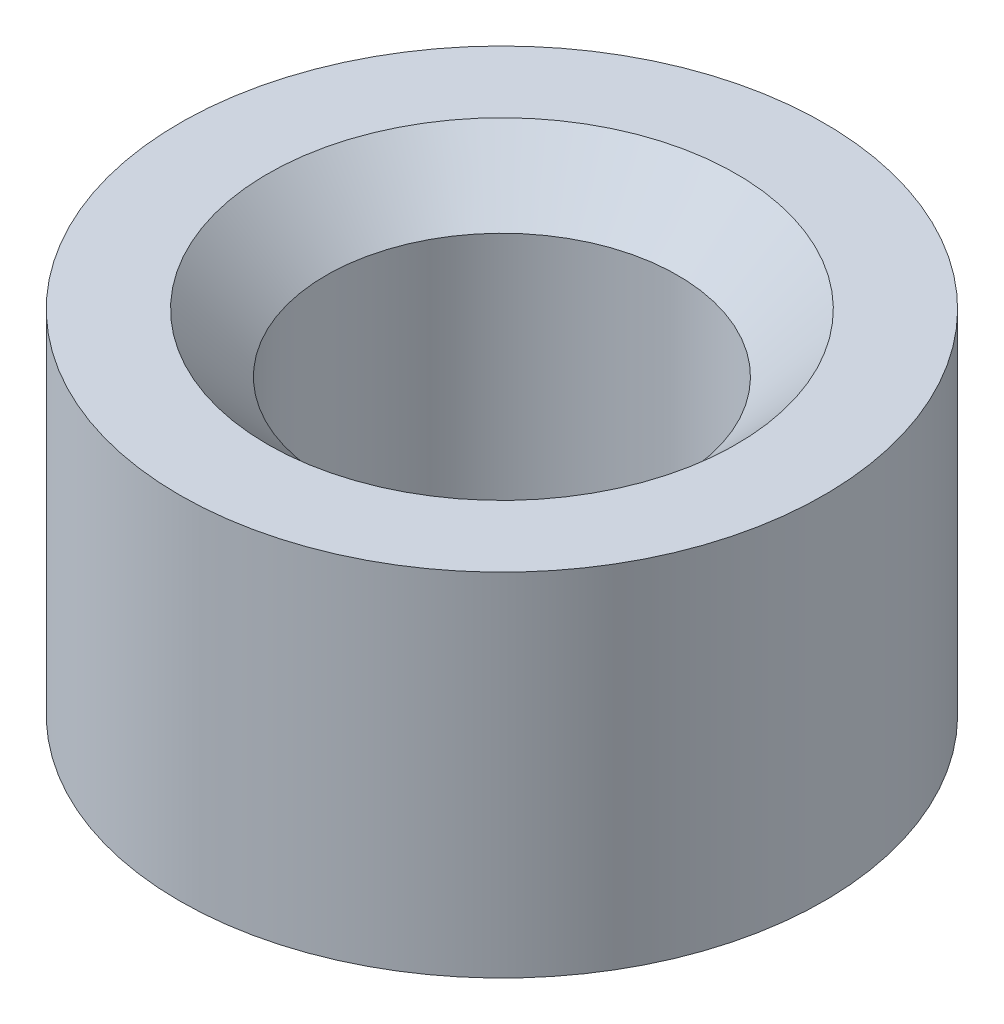
from build123d import *

# Parameters (mm, degrees)
SKETCH1_R           = 2.75
SKETCH1_R_2         = 1.5
BOSS_EXTRUDE1_DEPTH = 3
CHAMFER1_SIZE       = 0.5


with BuildPart() as part:
    # Sketch1 → Boss-Extrude1 (new body)
    with BuildSketch(Plane(origin=(0, 0, 0), x_dir=(1, 0, 0), z_dir=(0, 1, 0))):
        Circle(SKETCH1_R)
        Circle(SKETCH1_R_2, mode=Mode.SUBTRACT)
    extrude(amount=BOSS_EXTRUDE1_DEPTH)

    # Chamfer1
    chamfer1_edges = [part.edges().sort_by_distance(p)[0] for p in [
        (-1.5, 0, 0),
        (-1.5, 3, 0),
    ]]
    chamfer(chamfer1_edges, length=CHAMFER1_SIZE)


solid = part.part
